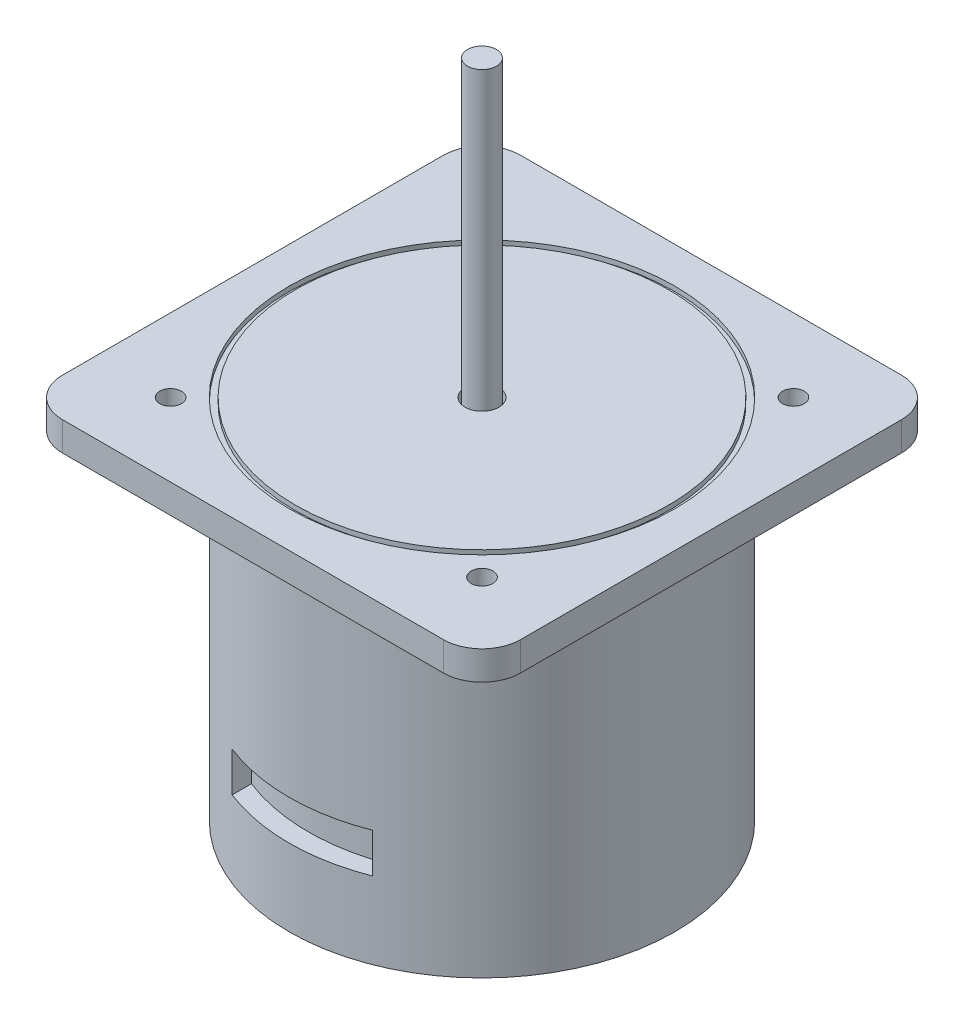
from build123d import *

# Parameters (mm, degrees)
SKETCH1_R                 = 40
BOSS_EXTRUDE1_DEPTH       = 70
SKETCH2_W                 = 95
SKETCH2_H                 = 95
BOSS_EXTRUDE2_DEPTH       = 6
SKETCH3_R                 = 40
SKETCH3_R_2               = 38.709273032
CUT_EXTRUDE1_DEPTH        = 1
SKETCH4_R                 = 3
BOSS_EXTRUDE3_DEPTH       = 61
FILLET1_R                 = 8
SKETCH6_R                 = 3.519560707
SKETCH6_R_2               = 3
CUT_EXTRUDE3_DEPTH        = 5
CUT_EXTRUDE4_REACH        = 158.583
CUT_EXTRUDE4_START_RADIUS = 40
CUT_EXTRUDE4_END_RADIUS   = 40
SKETCH8_W                 = 29.147137568
SKETCH8_H                 = 8.22098752
BOSS_EXTRUDE5_DEPTH       = 4
SKETCH10_R                = 2.25
CUT_EXTRUDE5_DEPTH        = 34


with BuildPart() as part:
    # Sketch1 → Boss-Extrude1 (new body)
    with BuildSketch(Plane(origin=(0, 0, 0), x_dir=(1, 0, 0), z_dir=(0, 1, 0))):
        with Locations(Location((0, 0, 0), (0, 0, 270))):
            Circle(SKETCH1_R)
    extrude(amount=BOSS_EXTRUDE1_DEPTH)

    # Sketch2 → Boss-Extrude2 (add)
    with BuildSketch(Plane(origin=(0, 70, 0), x_dir=(1, 0, 0), z_dir=(0, 1, 0))):
        Rectangle(SKETCH2_W, SKETCH2_H)
    extrude(amount=BOSS_EXTRUDE2_DEPTH)

    # Sketch3 → Cut-Extrude1 (cut)
    with BuildSketch(Plane(origin=(0, 76, 0), x_dir=(1, 0, 0), z_dir=(0, 1, 0))):
        with Locations(Location((0, 0, 0), (0, 0, 270))):
            Circle(SKETCH3_R)
        with Locations(Location((0, 0, 0), (0, 0, 270))):
            Circle(SKETCH3_R_2, mode=Mode.SUBTRACT)
    extrude(amount=-CUT_EXTRUDE1_DEPTH, mode=Mode.SUBTRACT)

    # Sketch4 → Boss-Extrude3 (add)
    with BuildSketch(Plane(origin=(0, 76, 0), x_dir=(1, 0, 0), z_dir=(0, 1, 0))):
        with Locations(Location((0, 0, 0), (0, 0, 90))):
            Circle(SKETCH4_R)
    extrude(amount=BOSS_EXTRUDE3_DEPTH)

    # Fillet1
    fillet1_edges = [part.edges().sort_by_distance(p)[0] for p in [
        (47.5, 73, 47.5),
        (47.5, 73, -47.5),
        (-47.5, 73, -47.5),
        (-47.5, 73, 47.5),
    ]]
    fillet(fillet1_edges, radius=FILLET1_R)

    # Sketch6 → Cut-Extrude3 (cut)
    with BuildSketch(Plane(origin=(0, 76, 0), x_dir=(1, 0, 0), z_dir=(0, 1, 0))):
        with Locations(Location((0, 0, 0), (0, 0, 270))):
            Circle(SKETCH6_R)
        with Locations(Location((0, 0, 0), (0, 0, 90))):
            Circle(SKETCH6_R_2, mode=Mode.SUBTRACT)
    extrude(amount=-CUT_EXTRUDE3_DEPTH, mode=Mode.SUBTRACT)

    # Cut-Extrude4: from a cylinder face, 158.583 long prism both ways, kept between that surface and its translate by the depth
    cut_extrude4_start = Plane(origin=(0, 20.055809, 0), z_dir=(0, -1, 0)) * Cylinder(CUT_EXTRUDE4_START_RADIUS, 398.166, mode=Mode.PRIVATE)
    cut_extrude4_end = Plane(origin=(0, 20.055809, -4), z_dir=(0, -1, 0)) * Cylinder(CUT_EXTRUDE4_END_RADIUS, 398.166, mode=Mode.PRIVATE)
    # Sketch8 → Cut-Extrude4 (cut, from a surface)
    with BuildSketch(Plane.XY, mode=Mode.PRIVATE) as cut_extrude4_sk1:
        with Locations((0, 20.055809212)):
            Rectangle(SKETCH8_W, SKETCH8_H)
    cut_extrude4_tool1 = extrude(cut_extrude4_sk1.sketch, amount=CUT_EXTRUDE4_REACH, both=True, mode=Mode.PRIVATE)
    add(((cut_extrude4_tool1 & cut_extrude4_start) - cut_extrude4_end).solids().sort_by_distance((0, 20.055809, 35.250652))[0], mode=Mode.SUBTRACT)

    # Sketch9 → Boss-Extrude5 (add)
    with BuildSketch(Plane.XZ):
        with BuildLine():
            ThreePointArc((-25.622676251, -4.384366141), (-27.880429407, -0.093420807), (-25.772900348, 4.273269294))
            Line((-25.772900348, 4.273269294), (-27.319093183, 6.289872554))
            ThreePointArc((-27.319093183, 6.289872554), (-29.604344551, 3.506882349), (-30.422381519, 0))
            ThreePointArc((-30.422381519, 0), (-29.542433802, -3.629669529), (-27.097976665, -6.453397238))
            Line((-27.097976665, -6.453397238), (-25.622676251, -4.384366141))
        make_face()
    boss_extrude5 = extrude(amount=BOSS_EXTRUDE5_DEPTH)

    # Mirror1: Boss-Extrude5 across plane
    add(boss_extrude5.mirror(Plane(origin=(0, 0, 0), x_dir=(0, 0, 1), z_dir=(1, 0, 0))))

    # Sketch10 → Cut-Extrude5 (cut)
    with BuildSketch(Plane(origin=(0, 76, 0), x_dir=(1, 0, 0), z_dir=(0, 1, 0))):
        with Locations(Location((-32.295599691, 32.295599691, 0), (0, 0, 270))):
            Circle(SKETCH10_R)
        with Locations(Location((32.295599691, 32.295599691, 0), (0, 0, 270))):
            Circle(SKETCH10_R)
        with Locations(Location((32.295599691, -32.295599691, 0), (0, 0, 270))):
            Circle(SKETCH10_R)
        with Locations(Location((-32.295599691, -32.295599691, 0), (0, 0, 270))):
            Circle(SKETCH10_R)
    extrude(amount=-CUT_EXTRUDE5_DEPTH, mode=Mode.SUBTRACT)


solid = part.part
